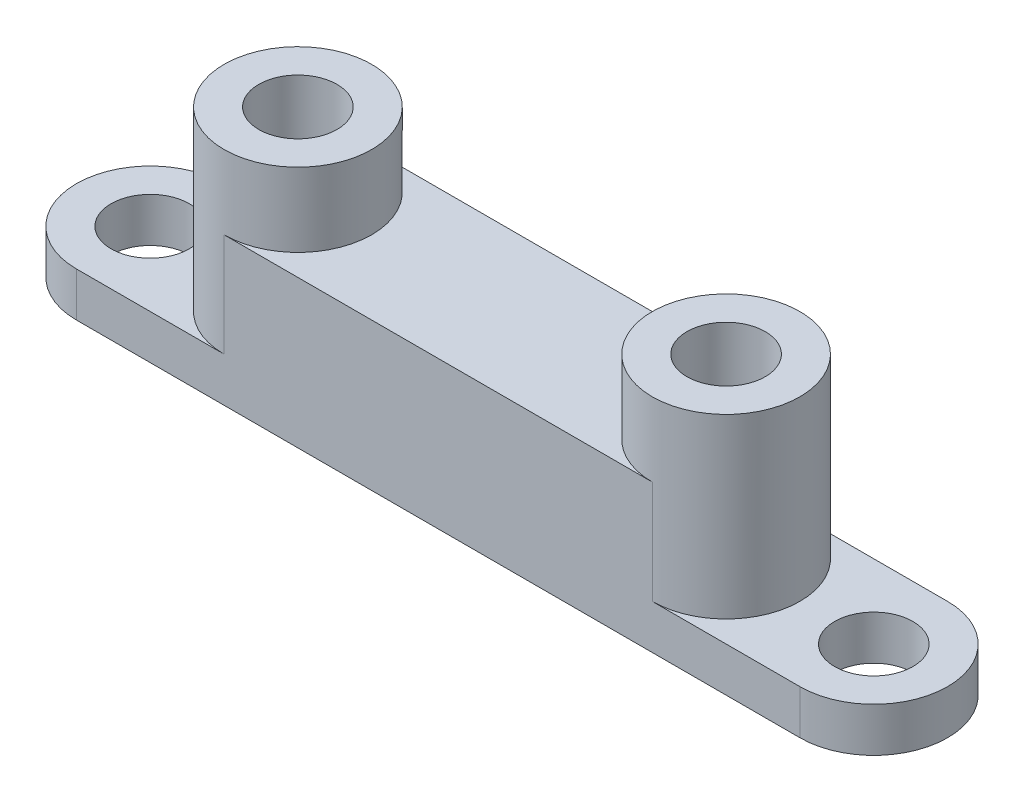
from build123d import *

# Parameters (mm, degrees)
ESQUISSE1_R             = 2.65
BOSS_EXTRU_1_DEPTH      = 15
ESQUISSE2_R             = 3.488871883
ESQUISSE2_R_2           = 3.573781448
BOSS_EXTRU_2_DEPTH      = 4
ENL_V_START             = -5
ENL_V_MAT_EXTRU_1_DEPTH = 5
ESQUISSE8_R             = 2.65
BOSS_EXTRU_3_DEPTH      = 3


with BuildPart() as part:
    # Esquisse1 → Boss.-Extru.1 (new body)
    with BuildSketch(Plane(origin=(0, 0, 0), x_dir=(1, 0, 0), z_dir=(0, 1, 0))):
        with BuildLine():
            Line((5, 0), (34, 0))
            ThreePointArc((34, 0), (39, 5), (34, 10))
            Line((34, 10), (5, 10))
            ThreePointArc((5, 10), (0, 5), (5, 0))
        make_face()
        with Locations(Location((5, 5, 0), (0, 0, 270))):
            Circle(ESQUISSE1_R, mode=Mode.SUBTRACT)
        with Locations(Location((34, 5, 0), (0, 0, 270))):
            Circle(ESQUISSE1_R, mode=Mode.SUBTRACT)
    extrude(amount=BOSS_EXTRU_1_DEPTH)

    # Esquisse2 → Boss.-Extru.2 (add)
    with BuildSketch(Plane.XZ):
        with Locations((5, -5)):
            Circle(ESQUISSE2_R)
        with Locations((34, -5)):
            Circle(ESQUISSE2_R_2)
    extrude(amount=-BOSS_EXTRU_2_DEPTH)

    # Esquisse3 → Enlèv. mat.-Extru.1 (cut)
    with BuildSketch(Plane(origin=(0, 15, 0), x_dir=(1, 0, 0), z_dir=(0, 1, 0)).offset(ENL_V_START)):
        with BuildLine():
            Line((5, 10), (34, 10))
            ThreePointArc((34, 10), (29, 5), (34, 0))
            Line((34, 0), (5, 0))
            ThreePointArc((5, 0), (10, 5), (5, 10))
        make_face()
    extrude(amount=ENL_V_MAT_EXTRU_1_DEPTH, mode=Mode.SUBTRACT)

    # Esquisse8 → Boss.-Extru.3 (add)
    with BuildSketch(Plane.XZ):
        with BuildLine():
            Line((44.001861421, -10), (-5.001861421, -10))
            ThreePointArc((-5.001861421, -10), (-10.001861421, -5), (-5.001861421, 0))
            Line((-5.001861421, 0), (44.001861421, 0))
            ThreePointArc((44.001861421, 0), (49.001861421, -5), (44.001861421, -10))
        make_face()
        with Locations(Location((-5.001861421, -5, 0), (0, 0, 270))):
            Circle(ESQUISSE8_R, mode=Mode.SUBTRACT)
        with Locations(Location((44.001861421, -5, 0), (0, 0, 270))):
            Circle(ESQUISSE8_R, mode=Mode.SUBTRACT)
    extrude(amount=-BOSS_EXTRU_3_DEPTH)


solid = part.part
